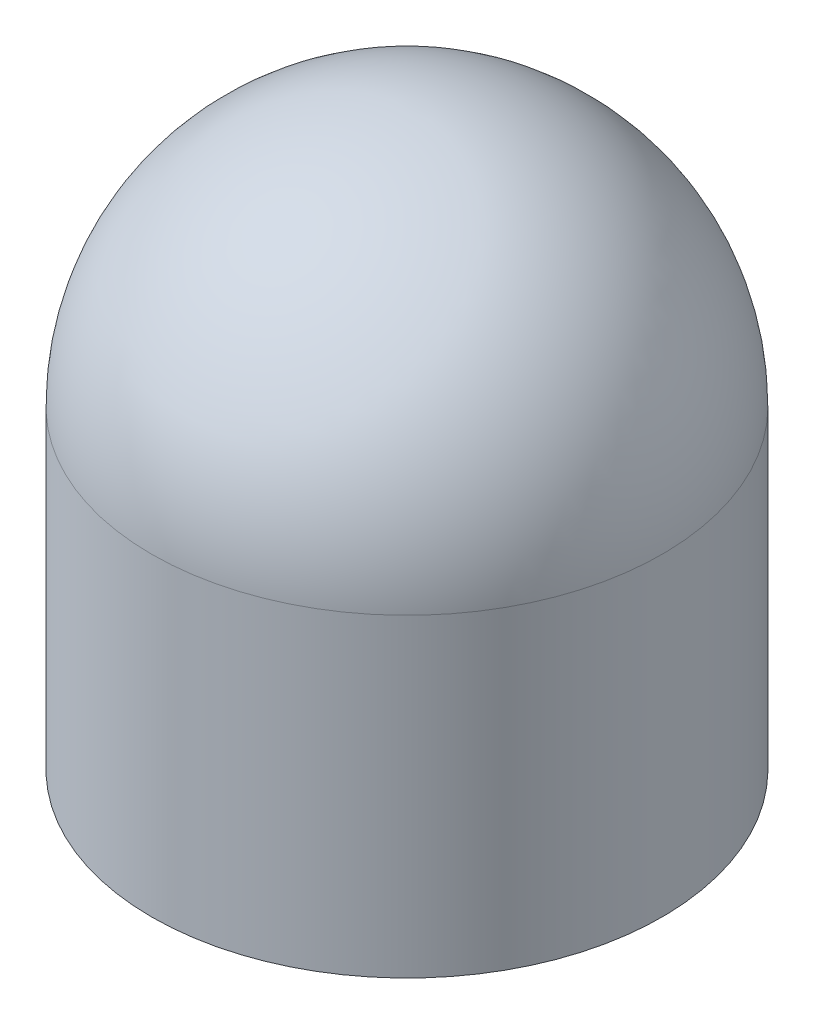
from build123d import *

# Parameters (mm, degrees)
SKETCH1_R           = 165.1
BOSS_EXTRUDE1_DEPTH = 203.2
REVOLVE1_ANGLE      = 180
SHELL1_T            = -2.54


with BuildPart() as part:
    # Sketch1 → Boss-Extrude1 (new body)
    with BuildSketch(Plane(origin=(0, 0, 0), x_dir=(1, 0, 0), z_dir=(0, 1, 0))):
        with Locations(Location((0, 0, 0), (0, 0, 270))):
            Circle(SKETCH1_R)
    extrude(amount=BOSS_EXTRUDE1_DEPTH)

    # Sketch2 → Revolve1 (revolve)
    with BuildSketch(Plane(origin=(0, 203.2, 0), x_dir=(1, 0, 0), z_dir=(0, 1, 0))):
        with BuildLine():
            Line((0, 165.1), (0, -165.1))
            ThreePointArc((0, -165.1), (165.1, 0), (0, 165.1))
        make_face()
    revolve(axis=Axis((0, 203.2, -165.1), (0, 0, 1)), revolution_arc=REVOLVE1_ANGLE)

    # Shell1
    shell1_openings = [part.faces().sort_by_distance(p)[0] for p in [
        (0, 0, 0),
    ]]
    offset(amount=SHELL1_T, openings=shell1_openings, kind=Kind.INTERSECTION)


solid = part.part
